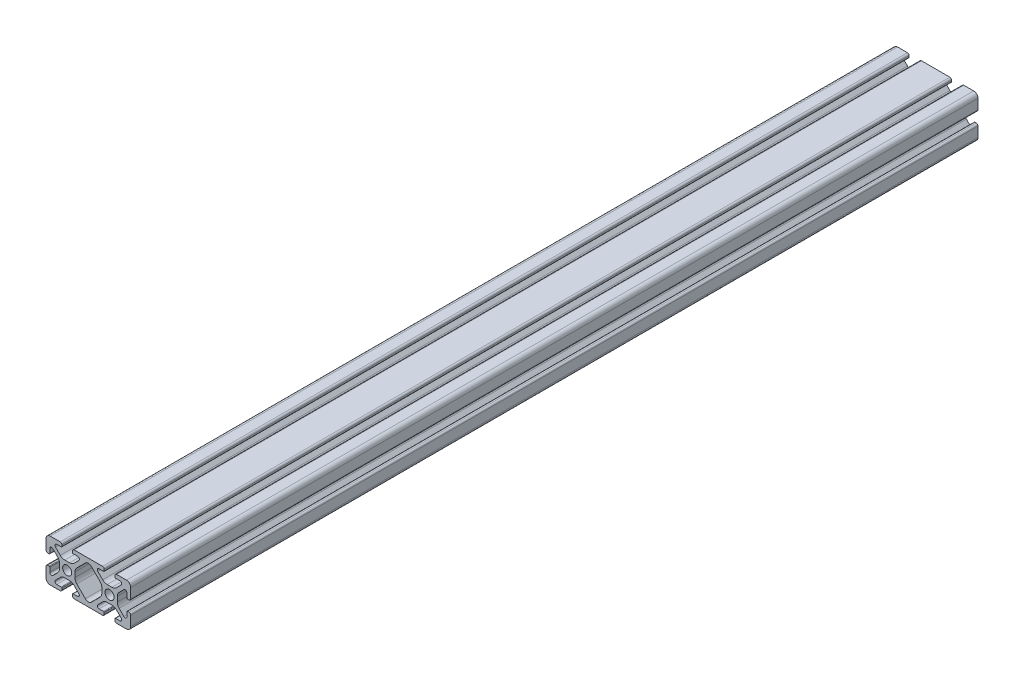
from build123d import *

# Parameters (mm, degrees)
CROQUIS1_R              = 2.15
SALIENTE_EXTRUIR1_DEPTH = 400


with BuildPart() as part:
    # Croquis1 → Saliente-Extruir1 (new body)
    with BuildSketch(Plane.XY.offset(20)):
        with BuildLine():
            Line((32.499999987, 1.499999997), (32.499999987, 0.800000002))
            ThreePointArc((32.499999987, 0.800000002), (32.734314563, 0.234314576), (33.29999999, 0))
            Line((33.29999999, 0), (38, 0))
            ThreePointArc((38, 0), (39.414213562, 0.585786438), (40, 2))
            Line((40, 2), (40, 6.700000003))
            ThreePointArc((40, 6.700000003), (39.765685425, 7.265685427), (39.2, 7.500000003))
            Line((39.2, 7.500000003), (38.499999996, 7.500000003))
            ThreePointArc((38.499999996, 7.500000003), (38.287867962, 7.412132037), (38.199999996, 7.200000003))
            Line((38.199999996, 7.200000003), (38.199999996, 5.082411612))
            ThreePointArc((38.199999996, 5.082411612), (37.686138518, 4.313363563), (36.778984492, 4.493807718))
            Line((36.778984492, 4.493807718), (34.528679652, 6.744112558))
            ThreePointArc((34.528679652, 6.744112558), (33.878361399, 7.717382603), (33.649999997, 8.865432898))
            Line((33.649999997, 8.865432898), (33.649999997, 11.134567109))
            ThreePointArc((33.649999997, 11.134567109), (33.878361399, 12.282617405), (34.528679653, 13.255887451))
            Line((34.528679653, 13.255887451), (36.778984498, 15.506192296))
            ThreePointArc((36.778984498, 15.506192296), (37.68613852, 15.686636451), (38.199999996, 14.917588405))
            Line((38.199999996, 14.917588405), (38.199999996, 12.800000003))
            ThreePointArc((38.199999996, 12.800000003), (38.287867963, 12.587867967), (38.499999999, 12.5))
            Line((38.499999999, 12.5), (39.199999998, 12.5))
            ThreePointArc((39.199999998, 12.5), (39.765685424, 12.734314576), (40, 13.300000002))
            Line((40, 13.300000002), (40, 18))
            ThreePointArc((40, 18), (39.414213562, 19.414213562), (38, 20))
            Line((38, 20), (33.299999987, 20))
            ThreePointArc((33.299999987, 20), (32.734314562, 19.765685425), (32.499999987, 19.2))
            Line((32.499999987, 19.2), (32.499999987, 18.499999997))
            ThreePointArc((32.499999987, 18.499999997), (32.587867953, 18.287867963), (32.799999987, 18.199999997))
            Line((32.799999987, 18.199999997), (34.917587986, 18.199999997))
            ThreePointArc((34.917587986, 18.199999997), (35.686635927, 17.686138592), (35.506191797, 16.778984693))
            Line((35.506191797, 16.778984693), (33.255886766, 14.528679662))
            ThreePointArc((33.255886766, 14.528679662), (32.282616721, 13.878361409), (31.134566426, 13.650000007))
            Line((31.134566426, 13.650000007), (28.86543289, 13.650000007))
            ThreePointArc((28.86543289, 13.650000007), (27.717382593, 13.878361409), (26.744112547, 14.528679663))
            Line((26.744112547, 14.528679663), (24.493807707, 16.778984503))
            ThreePointArc((24.493807707, 16.778984503), (24.313363553, 17.686138523), (25.082411597, 18.199999997))
            Line((25.082411597, 18.199999997), (27.199999997, 18.199999997))
            ThreePointArc((27.199999997, 18.199999997), (27.412132033, 18.287867964), (27.5, 18.5))
            Line((27.5, 18.5), (27.5, 19.199999998))
            ThreePointArc((27.5, 19.199999998), (27.265685424, 19.765685424), (26.699999997, 20))
            Line((26.699999997, 20), (13.299999987, 20))
            ThreePointArc((13.299999987, 20), (12.734314562, 19.765685425), (12.499999987, 19.2))
            Line((12.499999987, 19.2), (12.499999987, 18.499999997))
            ThreePointArc((12.499999987, 18.499999997), (12.587867953, 18.287867963), (12.799999987, 18.199999997))
            Line((12.799999987, 18.199999997), (14.917588389, 18.199999997))
            ThreePointArc((14.917588389, 18.199999997), (15.686636438, 17.686138519), (15.506192283, 16.778984493))
            Line((15.506192283, 16.778984493), (13.255887452, 14.528679662))
            ThreePointArc((13.255887452, 14.528679662), (12.282617407, 13.878361409), (11.134567112, 13.650000007))
            Line((11.134567112, 13.650000007), (8.86543289, 13.650000007))
            ThreePointArc((8.86543289, 13.650000007), (7.717382593, 13.878361409), (6.744112547, 14.528679663))
            Line((6.744112547, 14.528679663), (4.493807707, 16.778984503))
            ThreePointArc((4.493807707, 16.778984503), (4.313363553, 17.686138523), (5.082411597, 18.199999997))
            Line((5.082411597, 18.199999997), (7.199999997, 18.199999997))
            ThreePointArc((7.199999997, 18.199999997), (7.412132033, 18.287867964), (7.5, 18.5))
            Line((7.5, 18.5), (7.5, 19.199999998))
            ThreePointArc((7.5, 19.199999998), (7.265685424, 19.765685424), (6.699999997, 20))
            Line((6.699999997, 20), (2, 20))
            ThreePointArc((2, 20), (0.585786438, 19.414213562), (0, 18))
            Line((0, 18), (0, 13.3))
            ThreePointArc((0, 13.3), (0.234314575, 12.734314575), (0.8, 12.5))
            Line((0.8, 12.5), (1.500000005, 12.5))
            ThreePointArc((1.500000005, 12.5), (1.71213204, 12.587867966), (1.800000005, 12.8))
            Line((1.800000005, 12.8), (1.800000005, 14.91758839))
            ThreePointArc((1.800000005, 14.91758839), (2.313861483, 15.686636439), (3.22101551, 15.506192284))
            Line((3.22101551, 15.506192284), (5.471320341, 13.255887453))
            ThreePointArc((5.471320341, 13.255887453), (6.121638594, 12.282617408), (6.349999996, 11.134567113))
            Line((6.349999996, 11.134567113), (6.349999996, 8.865432892))
            ThreePointArc((6.349999996, 8.865432892), (6.121638593, 7.717382596), (5.47132034, 6.74411255))
            Line((5.47132034, 6.74411255), (3.2210155, 4.49380771))
            ThreePointArc((3.2210155, 4.49380771), (2.31386148, 4.313363556), (1.800000005, 5.0824116))
            Line((1.800000005, 5.0824116), (1.800000005, 7.2))
            ThreePointArc((1.800000005, 7.2), (1.712132039, 7.412132036), (1.500000003, 7.500000003))
            Line((1.500000003, 7.500000003), (0.800000003, 7.500000003))
            ThreePointArc((0.800000003, 7.500000003), (0.234314576, 7.265685427), (0, 6.7))
            Line((0, 6.7), (0, 2))
            ThreePointArc((0, 2), (0.585786438, 0.585786438), (2, 0))
            Line((2, 0), (6.7, 0))
            ThreePointArc((6.7, 0), (7.265685425, 0.234314575), (7.5, 0.8))
            Line((7.5, 0.8), (7.5, 1.5))
            ThreePointArc((7.5, 1.5), (7.412132034, 1.712132034), (7.2, 1.8))
            Line((7.2, 1.8), (5.0824116, 1.8))
            ThreePointArc((5.0824116, 1.8), (4.313363551, 2.313861478), (4.493807706, 3.221015504))
            Line((4.493807706, 3.221015504), (6.744112546, 5.471320344))
            ThreePointArc((6.744112546, 5.471320344), (7.717382591, 6.121638597), (8.865432886, 6.349999999))
            Line((8.865432886, 6.349999999), (11.134567108, 6.349999999))
            ThreePointArc((11.134567108, 6.349999999), (12.282617404, 6.121638597), (13.25588745, 5.471320343))
            Line((13.25588745, 5.471320343), (15.506192295, 3.221015498))
            ThreePointArc((15.506192295, 3.221015498), (15.686636449, 2.313861476), (14.917588403, 1.8))
            Line((14.917588403, 1.8), (12.79999999, 1.8))
            ThreePointArc((12.79999999, 1.8), (12.587867954, 1.712132033), (12.499999987, 1.499999997))
            Line((12.499999987, 1.499999997), (12.499999987, 0.800000003))
            ThreePointArc((12.499999987, 0.800000003), (12.734314563, 0.234314576), (13.29999999, 0))
            Line((13.29999999, 0), (26.7, 0))
            ThreePointArc((26.7, 0), (27.265685425, 0.234314575), (27.5, 0.8))
            Line((27.5, 0.8), (27.5, 1.5))
            ThreePointArc((27.5, 1.5), (27.412132034, 1.712132034), (27.2, 1.8))
            Line((27.2, 1.8), (25.0824116, 1.8))
            ThreePointArc((25.0824116, 1.8), (24.313363551, 2.313861478), (24.493807706, 3.221015504))
            Line((24.493807706, 3.221015504), (26.744112546, 5.471320344))
            ThreePointArc((26.744112546, 5.471320344), (27.717382591, 6.121638597), (28.865432886, 6.349999999))
            Line((28.865432886, 6.349999999), (31.134567114, 6.349999999))
            ThreePointArc((31.134567114, 6.349999999), (32.282617411, 6.121638597), (33.255887457, 5.471320343))
            Line((33.255887457, 5.471320343), (35.506192392, 3.221015408))
            ThreePointArc((35.506192392, 3.221015408), (35.686636535, 2.313861443), (34.917588538, 1.8))
            Line((34.917588538, 1.8), (32.79999999, 1.8))
            ThreePointArc((32.79999999, 1.8), (32.587867954, 1.712132033), (32.499999987, 1.499999997))
        make_face()
        with Locations((10, 10)):
            Circle(CROQUIS1_R, mode=Mode.SUBTRACT)
        with Locations((30, 10)):
            Circle(CROQUIS1_R, mode=Mode.SUBTRACT)
        with BuildLine():
            Line((18.585786097, 2.687006113), (14.528679097, 6.744113113))
            ThreePointArc((14.528679097, 6.744113113), (13.878360843, 7.717383159), (13.649999441, 8.865433456))
            Line((13.649999441, 8.865433456), (13.649999441, 11.134566554))
            ThreePointArc((13.649999441, 11.134566554), (13.878360843, 12.282616849), (14.528679096, 13.255886895))
            Line((14.528679096, 13.255886895), (18.585786441, 17.312994239))
            ThreePointArc((18.585786441, 17.312994239), (20.000000001, 17.898780676), (21.414213561, 17.312994239))
            Line((21.414213561, 17.312994239), (25.471320216, 13.255887584))
            ThreePointArc((25.471320216, 13.255887584), (26.12163847, 12.282617538), (26.349999872, 11.13456724))
            Line((26.349999872, 11.13456724), (26.349999872, 8.865433454))
            ThreePointArc((26.349999872, 8.865433454), (26.12163847, 7.717383158), (25.471320217, 6.744113113))
            Line((25.471320217, 6.744113113), (21.414213217, 2.687006113))
            ThreePointArc((21.414213217, 2.687006113), (19.999999657, 2.101219676), (18.585786097, 2.687006113))
        make_face(mode=Mode.SUBTRACT)
    extrude(amount=-SALIENTE_EXTRUIR1_DEPTH)


solid = part.part
